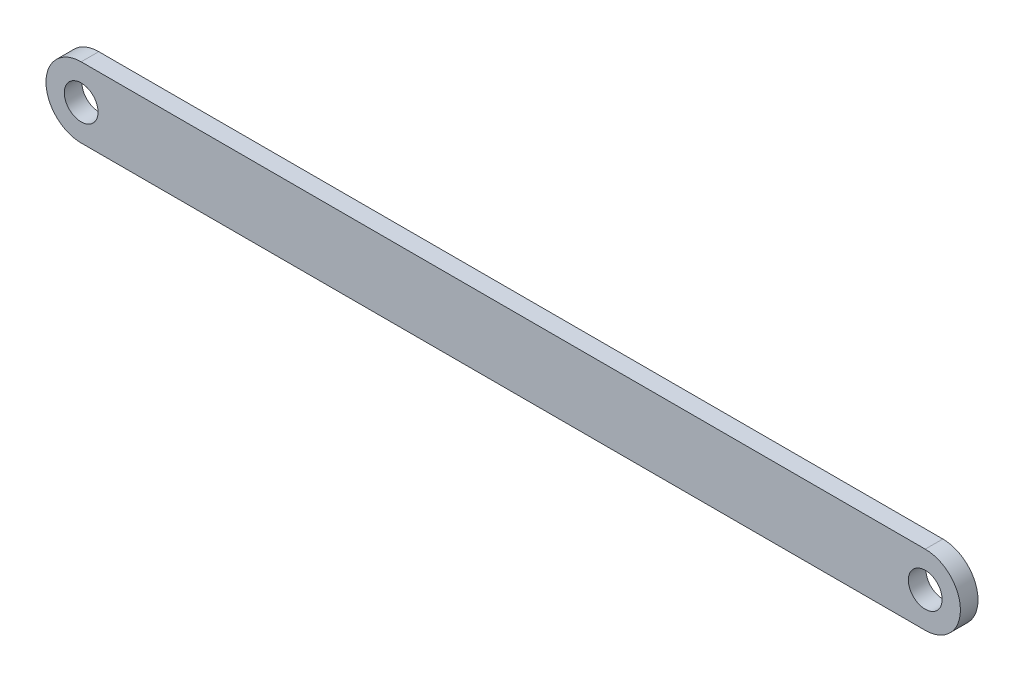
from build123d import *

# Parameters (mm, degrees)
SKETCH1_R           = 3.048
BOSS_EXTRUDE1_DEPTH = 3.175


with BuildPart() as part:
    # Sketch1 → Boss-Extrude1 (new body)
    with BuildSketch(Plane.XY):
        with BuildLine():
            Line((-76.2, -6.35), (76.2, -6.35))
            ThreePointArc((76.2, -6.35), (82.55, 0), (76.2, 6.35))
            Line((76.2, 6.35), (-76.2, 6.35))
            ThreePointArc((-76.2, 6.35), (-82.55, 0), (-76.2, -6.35))
        make_face()
        with Locations((-76.2, 0)):
            Circle(SKETCH1_R, mode=Mode.SUBTRACT)
        with Locations((76.2, 0)):
            Circle(SKETCH1_R, mode=Mode.SUBTRACT)
    extrude(amount=BOSS_EXTRUDE1_DEPTH)


solid = part.part
